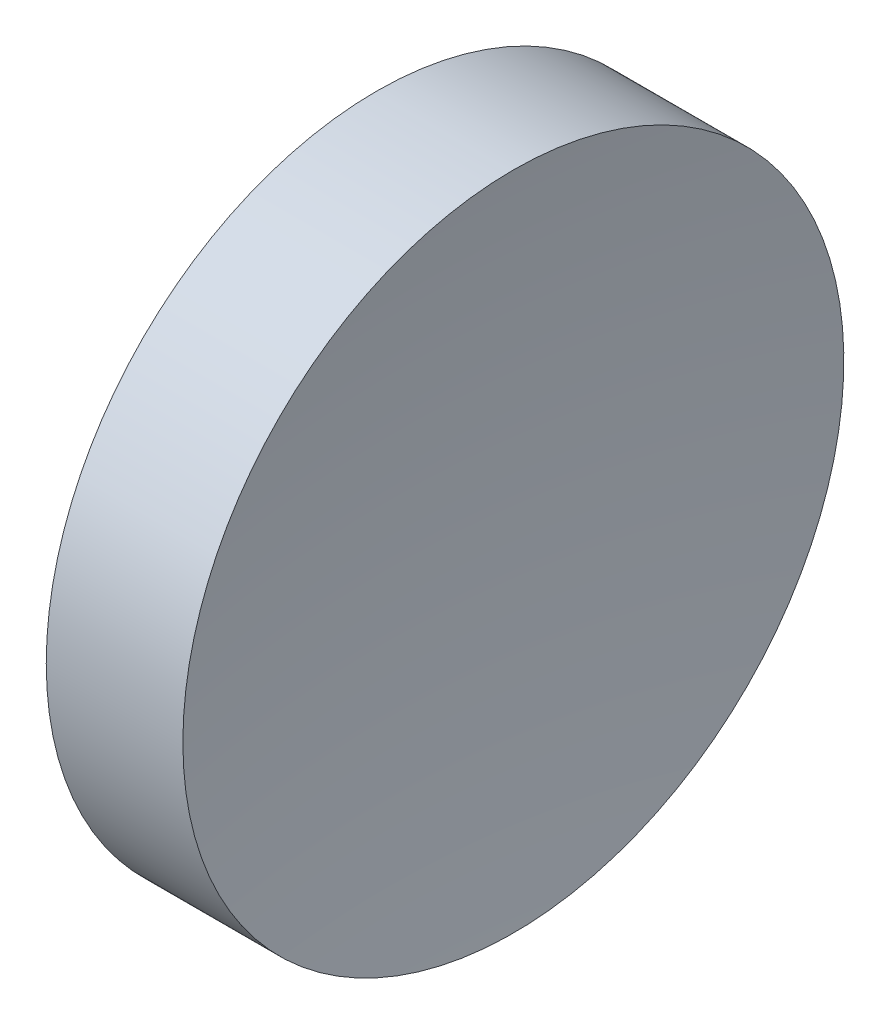
from build123d import *


with BuildPart() as part:
    # 草图1 → 旋转1 (revolve)
    with BuildSketch(Plane.XY):
        with BuildLine():
            Line((121.852703446, 65.222602873), (118.352703446, 65.222602873))
            ThreePointArc((118.352703446, 65.222602873), (118.133686773, 71.587657442), (117.477672784, 77.922602873))
            Line((117.477672784, 77.922602873), (120.102703446, 77.922602873))
            Line((120.102703446, 77.922602873), (122.727734109, 77.922602873))
            ThreePointArc((122.727734109, 77.922602873), (122.07172012, 71.587657442), (121.852703446, 65.222602873))
        make_face()
    revolve(axis=Axis((109.936935226, 65.222602873, 0), (1, 0, 0)))


solid = part.part
